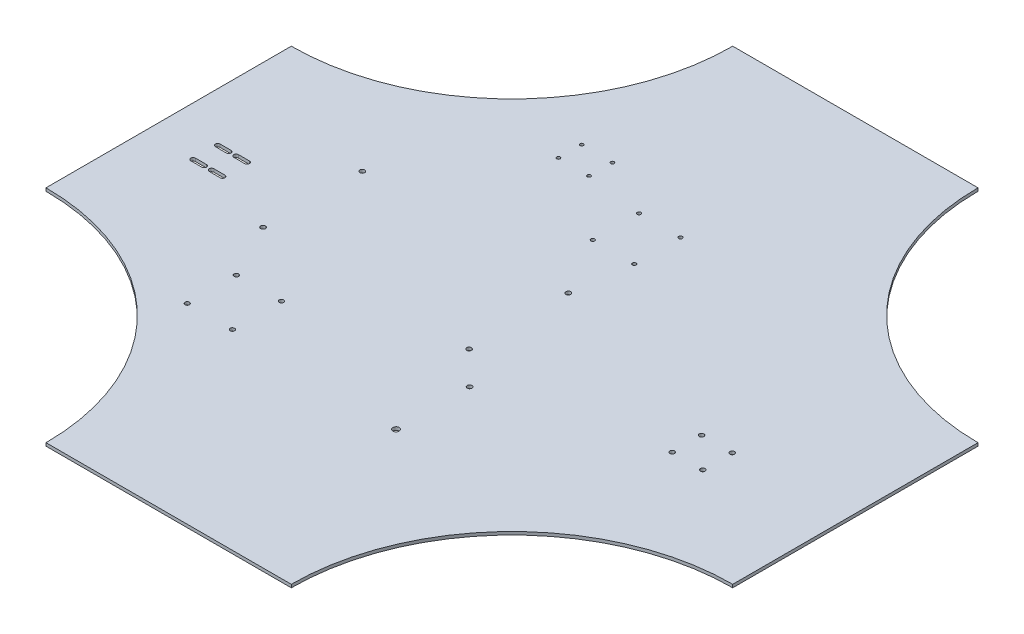
from build123d import *

# Parameters (mm, degrees)
BOSS_EXTRUDE1_DEPTH     = 3.175
CUT_EXTRUDE1_DEPTH      = 1
CUT_EXTRUDE1_DEPTH_BACK = 4.175
SKETCH4_R               = 2.413
CUT_EXTRUDE2_DEPTH      = 4.175
SKETCH5_R               = 2.5
SKETCH5_R_2             = 2.47796547
CUT_EXTRUDE3_DEPTH      = 4.175
SKETCH6_R               = 2.321781934
SKETCH6_R_2             = 3.272341149
SKETCH6_R_3             = 2.5
SKETCH6_R_4             = 1.905
SKETCH6_R_5             = 1.75
CUT_EXTRUDE4_DEPTH      = 4.175


with BuildPart() as part:
    # Sketch1 → Boss-Extrude1 (new body)
    with BuildSketch(Plane(origin=(0, 0, 0), x_dir=(1, 0, 0), z_dir=(0, 1, 0))):
        with BuildLine():
            Line((-127, -355.6), (127, -355.6))
            ThreePointArc((127, -355.6), (193.955389821, -193.955389821), (355.6, -127))
            Line((355.6, -127), (355.6, 127))
            ThreePointArc((355.6, 127), (193.955389821, 193.955389821), (127, 355.6))
            Line((127, 355.6), (-127, 355.6))
            ThreePointArc((-127, 355.6), (-193.955389821, 193.955389821), (-355.6, 127))
            Line((-355.6, 127), (-355.6, -127))
            ThreePointArc((-355.6, -127), (-193.955389821, -193.955389821), (-127, -355.6))
        make_face()
    extrude(amount=BOSS_EXTRUDE1_DEPTH)

    # Sketch2 → Cut-Extrude1 (cut, two sides)
    with BuildSketch(Plane(origin=(0, 3.175, 0), x_dir=(1, 0, 0), z_dir=(0, 1, 0))) as cut_extrude1_sk:
        with BuildLine():
            Line((-304.8, 2.413), (-293.37, 2.413))
            ThreePointArc((-293.37, 2.413), (-290.957, 0), (-293.37, -2.413))
            Line((-293.37, -2.413), (-304.8, -2.413))
            ThreePointArc((-304.8, -2.413), (-307.213, 0), (-304.8, 2.413))
        make_face()
        with BuildLine():
            Line((-304.8, -22.987), (-293.37, -22.987))
            ThreePointArc((-293.37, -22.987), (-290.957, -25.4), (-293.37, -27.813))
            Line((-293.37, -27.813), (-304.8, -27.813))
            ThreePointArc((-304.8, -27.813), (-307.213, -25.4), (-304.8, -22.987))
        make_face()
        with BuildLine():
            Line((-285.75, -2.413), (-274.32, -2.413))
            ThreePointArc((-274.32, -2.413), (-271.907, 0), (-274.32, 2.413))
            Line((-274.32, 2.413), (-285.75, 2.413))
            ThreePointArc((-285.75, 2.413), (-288.163, 0), (-285.75, -2.413))
        make_face()
        with BuildLine():
            Line((-285.75, -22.987), (-274.32, -22.987))
            ThreePointArc((-274.32, -22.987), (-271.907, -25.4), (-274.32, -27.813))
            Line((-274.32, -27.813), (-285.75, -27.813))
            ThreePointArc((-285.75, -27.813), (-288.163, -25.4), (-285.75, -22.987))
        make_face()
    extrude(amount=CUT_EXTRUDE1_DEPTH, mode=Mode.SUBTRACT)
    extrude(cut_extrude1_sk.sketch, amount=-CUT_EXTRUDE1_DEPTH_BACK, mode=Mode.SUBTRACT)

    # Sketch4 → Cut-Extrude2 (cut, through all)
    with BuildSketch(Plane(origin=(0, 3.175, 0), x_dir=(1, 0, 0), z_dir=(0, 1, 0))):
        with Locations((237.49, -9.430177049)):
            Circle(SKETCH4_R)
        with Locations((205.74, -9.430177049)):
            Circle(SKETCH4_R)
        with Locations((237.49, -39.910177049)):
            Circle(SKETCH4_R)
        with Locations((205.74, -39.910177049)):
            Circle(SKETCH4_R)
    extrude(amount=-CUT_EXTRUDE2_DEPTH, mode=Mode.SUBTRACT)

    # Sketch5 → Cut-Extrude3 (cut, through all)
    with BuildSketch(Plane.XZ):
        with Locations((-207.790149601, 50.01656837)):
            Circle(SKETCH5_R)
        with Locations((-206.624048203, -51.576739518)):
            Circle(SKETCH5_R)
        with Locations((8.09562966, 52.494533839)):
            Circle(SKETCH5_R_2)
        with Locations((9.261731058, -49.098774048)):
            Circle(SKETCH5_R)
    extrude(amount=-CUT_EXTRUDE3_DEPTH, mode=Mode.SUBTRACT)

    # Sketch6 → Cut-Extrude4 (cut, through all)
    with BuildSketch(Plane.XZ):
        with Locations((-131.96570437, 157.594741445)):
            Circle(SKETCH6_R)
        with Locations((-131.96570437, 106.794741445)):
            Circle(SKETCH6_R)
        with Locations((-178.700591901, 106.794741445)):
            Circle(SKETCH6_R)
        with Locations((-178.700591901, 157.594741445)):
            Circle(SKETCH6_R)
        with Locations((42.265908941, 162.337536061)):
            Circle(SKETCH6_R_2)
        with Locations((42.265908941, 86.137536061)):
            Circle(SKETCH6_R_3)
        with Locations((17.371687145, -109.265722508)):
            Circle(SKETCH6_R_4)
        with Locations((-25.681149945, -109.384160374)):
            Circle(SKETCH6_R_4)
        with Locations((-25.549785233, -157.135979683)):
            Circle(SKETCH6_R_4)
        with Locations((17.503045383, -157.015188359)):
            Circle(SKETCH6_R_4)
        with Locations((-84.882409293, -188.871278488)):
            Circle(SKETCH6_R_5)
        with Locations((-85.091846145, -164.872192335)):
            Circle(SKETCH6_R_5)
        with Locations((-116.881190831, -189.150527624)):
            Circle(SKETCH6_R_5)
        with Locations((-117.090627683, -165.151441471)):
            Circle(SKETCH6_R_5)
    extrude(amount=-CUT_EXTRUDE4_DEPTH, mode=Mode.SUBTRACT)


solid = part.part
